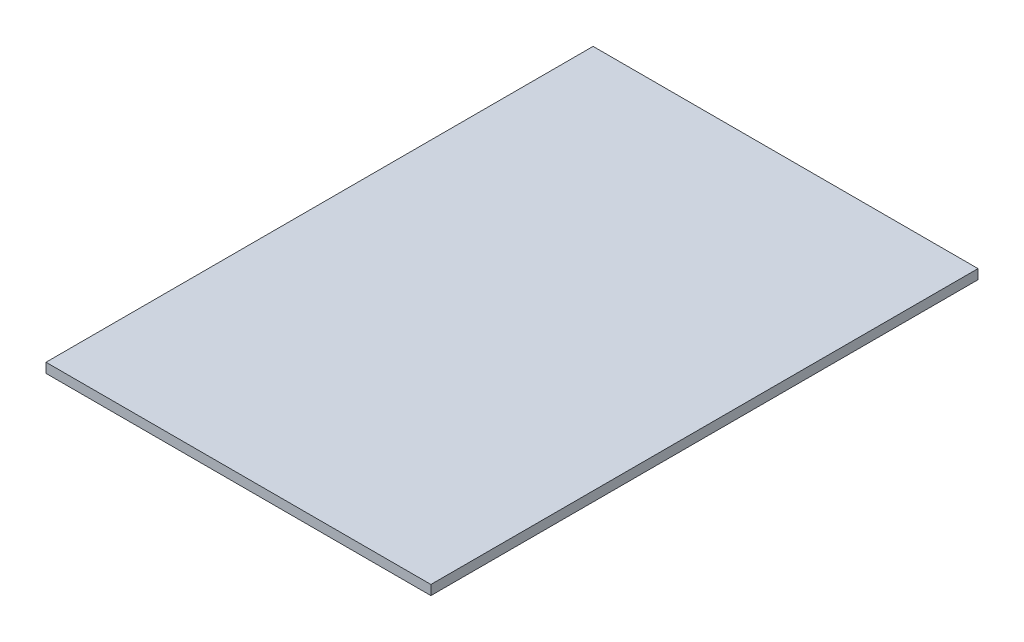
from build123d import *

# Parameters (mm, degrees)
SKETCH1_W           = 79.5
SKETCH1_H           = 113
BOSS_EXTRUDE1_DEPTH = 2


with BuildPart() as part:
    # Sketch1 → Boss-Extrude1 (new body)
    with BuildSketch(Plane(origin=(0, 0, 0), x_dir=(1, 0, 0), z_dir=(0, 1, 0))):
        with Locations((39.75, 56.5)):
            Rectangle(SKETCH1_W, SKETCH1_H)
    extrude(amount=BOSS_EXTRUDE1_DEPTH)


solid = part.part
